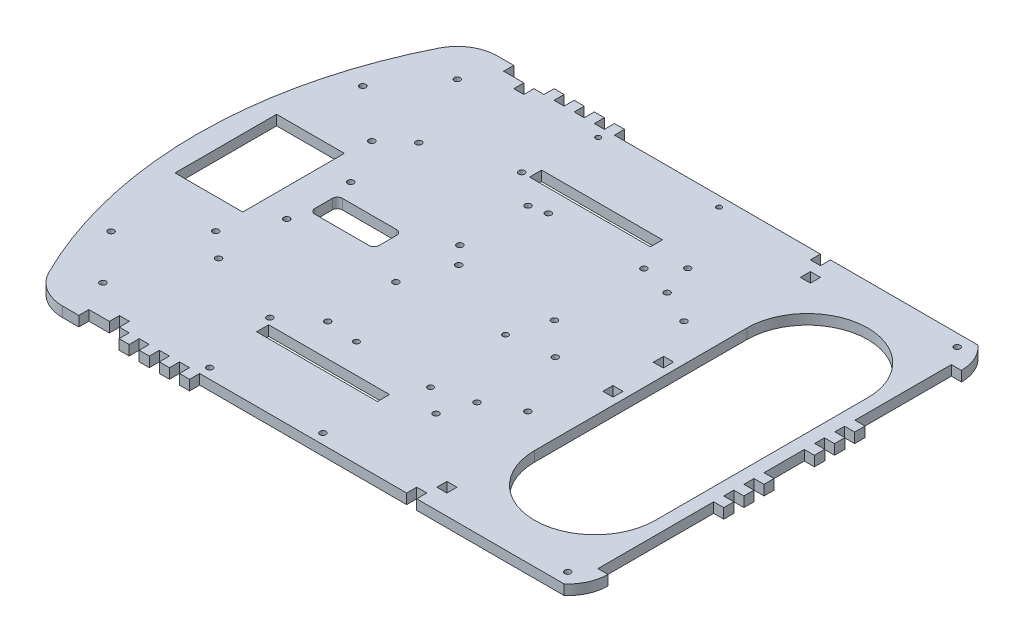
from build123d import *

# Parameters (mm, degrees)
MAIN_BASE_SKETCH_R   = 1.905
MAIN_BASE_SKETCH_R_2 = 1.5875
MAIN_BASE_SKETCH_W   = 6.302603838
MAIN_BASE_SKETCH_H   = 6.555527471
MAIN_BASE_SKETCH_W_2 = 6.35
MAIN_BASE_SKETCH_H_2 = 6.35
MAIN_BASE_SKETCH_W_3 = 76.2
MAIN_BASE_SKETCH_H_3 = 7.62
MAIN_BASE_DEPTH      = 6.35
SKETCH1_R            = 1.905
SKETCH1_R_2          = 1.796
CUT_EXTRUDE1_DEPTH   = 7.35


with BuildPart() as part:
    # main_base_sketch → main_base (new body)
    with BuildSketch(Plane(origin=(0, 0, 0), x_dir=(1, 0, 0), z_dir=(0, 1, 0))):
        with BuildLine():
            Line((-94.961375831, 124.478458264), (-82.261375831, 124.478458264))
            Line((-82.261375831, 124.478458264), (-82.261375831, 118.128458264))
            Line((-82.261375831, 118.128458264), (-75.911375831, 118.128458264))
            Line((-75.911375831, 118.128458264), (-75.911375831, 124.478458264))
            Line((-75.911375831, 124.478458264), (-69.561375831, 124.478458264))
            Line((-69.561375831, 124.478458264), (-69.561375831, 130.828458264))
            Line((-69.561375831, 130.828458264), (-63.211375831, 130.828458264))
            Line((-63.211375831, 130.828458264), (-63.211375831, 124.478458264))
            Line((-63.211375831, 124.478458264), (-56.861375831, 124.478458264))
            Line((-56.861375831, 124.478458264), (-56.861375831, 130.828458264))
            Line((-56.861375831, 130.828458264), (-50.511375831, 130.828458264))
            Line((-50.511375831, 130.828458264), (-50.511375831, 124.478458264))
            Line((-50.511375831, 124.478458264), (-44.161375831, 124.478458264))
            Line((-44.161375831, 124.478458264), (-44.161375831, 130.828458264))
            Line((-44.161375831, 130.828458264), (-37.811375831, 130.828458264))
            Line((-37.811375831, 130.828458264), (-37.811375831, 124.478458264))
            Line((-37.811375831, 124.478458264), (-31.461375831, 124.478458264))
            Line((-31.461375831, 124.478458264), (-31.461375831, 130.828458264))
            Line((-31.461375831, 130.828458264), (-25.111375831, 130.828458264))
            Line((-25.111375831, 130.828458264), (-25.111375831, 124.478458264))
            Line((-25.111375831, 124.478458264), (104.775, 124.478458264))
            Line((104.775, 124.478458264), (104.775, 118.128458264))
            Line((104.775, 118.128458264), (111.125, 118.128458264))
            Line((111.125, 118.128458264), (111.125, 124.478458264))
            Line((111.125, 124.478458264), (113.566844105, 124.478458264))
            Line((113.566844105, 124.478458264), (204.125520825, 124.478458264))
            ThreePointArc((204.125520825, 124.478458264), (210.475520825, 115.878979089), (212.725, 105.428458264))
            Line((212.725, 105.428458264), (206.375, 105.428458264))
            Line((206.375, 105.428458264), (206.375, 44.655527471))
            Line((206.375, 44.655527471), (212.725, 44.655527471))
            Line((212.725, 44.655527471), (212.725, 38.1))
            Line((212.725, 38.1), (206.375, 38.1))
            Line((206.375, 38.1), (206.375, 31.955527471))
            Line((206.375, 31.955527471), (212.725, 31.955527471))
            Line((212.725, 31.955527471), (212.725, 25.4))
            Line((212.725, 25.4), (206.375, 25.4))
            Line((206.375, 25.4), (206.375, 24.179190074))
            Line((206.375, 24.179190074), (206.375, 19.255527471))
            Line((206.375, 19.255527471), (212.725, 19.255527471))
            Line((212.725, 19.255527471), (212.725, 12.7))
            Line((212.725, 12.7), (206.375, 12.7))
            Line((206.375, 12.7), (206.375, -12.7))
            Line((206.375, -12.7), (212.725, -12.7))
            Line((212.725, -12.7), (212.725, -19.05))
            Line((212.725, -19.05), (206.375, -19.05))
            Line((206.375, -19.05), (206.375, -25.4))
            Line((206.375, -25.4), (212.725, -25.4))
            Line((212.725, -25.4), (212.725, -31.75))
            Line((212.725, -31.75), (206.375, -31.75))
            Line((206.375, -31.75), (206.375, -38.1))
            Line((206.375, -38.1), (212.725, -38.1))
            Line((212.725, -38.1), (212.725, -44.45))
            Line((212.725, -44.45), (206.375, -44.45))
            Line((206.375, -44.45), (206.375, -117.410242597))
            Line((206.375, -117.410242597), (212.725, -117.410242597))
            ThreePointArc((212.725, -117.410242597), (210.475520825, -127.860763422), (204.125520825, -136.460242597))
            Line((204.125520825, -136.460242597), (111.125, -136.460242597))
            Line((111.125, -136.460242597), (111.125, -130.101785028))
            Line((111.125, -130.101785028), (104.775, -130.101785028))
            Line((104.775, -130.101785028), (104.775, -136.460242597))
            Line((104.775, -136.460242597), (-25.751645083, -136.460242597))
            Line((-25.751645083, -136.460242597), (-25.751645083, -142.810242597))
            Line((-25.751645083, -142.810242597), (-32.101645083, -142.810242597))
            Line((-32.101645083, -142.810242597), (-32.101645083, -136.460242597))
            Line((-32.101645083, -136.460242597), (-38.451645083, -136.460242597))
            Line((-38.451645083, -136.460242597), (-38.451645083, -142.810242597))
            Line((-38.451645083, -142.810242597), (-44.801645083, -142.810242597))
            Line((-44.801645083, -142.810242597), (-44.801645083, -136.460242597))
            Line((-44.801645083, -136.460242597), (-51.151645083, -136.460242597))
            Line((-51.151645083, -136.460242597), (-51.151645083, -142.810242597))
            Line((-51.151645083, -142.810242597), (-57.501645083, -142.810242597))
            Line((-57.501645083, -142.810242597), (-57.501645083, -136.460242597))
            Line((-57.501645083, -136.460242597), (-63.851645083, -136.460242597))
            Line((-63.851645083, -136.460242597), (-63.851645083, -142.810242597))
            Line((-63.851645083, -142.810242597), (-70.201645083, -142.810242597))
            Line((-70.201645083, -142.810242597), (-70.201645083, -136.460242597))
            Line((-70.201645083, -136.460242597), (-76.408932816, -136.460242597))
            Line((-76.408932816, -136.460242597), (-76.408932816, -130.101785028))
            Line((-76.408932816, -130.101785028), (-82.6643, -130.101785028))
            Line((-82.6643, -130.101785028), (-82.6643, -136.460242597))
            Line((-82.6643, -136.460242597), (-95.601645083, -136.460242597))
            Line((-95.601645083, -136.460242597), (-95.601645083, -142.810242597))
            Line((-95.601645083, -142.810242597), (-105.798207048, -142.810242597))
            ThreePointArc((-105.798207048, -142.810242597), (-119.167015715, -139.007347839), (-128.532661201, -128.737404395))
            ThreePointArc((-128.532661201, -128.737404395), (-157.286213724, -5.861503432), (-127.918775374, 116.869125935))
            ThreePointArc((-127.918775374, 116.869125935), (-118.556014486, 127.058910858), (-105.241228699, 130.828458264))
            Line((-105.241228699, 130.828458264), (-94.961375831, 130.828458264))
            Line((-94.961375831, 130.828458264), (-94.961375831, 124.478458264))
        make_face()
        with Locations((-131.296368682, 71.963600743)):
            Circle(MAIN_BASE_SKETCH_R, mode=Mode.SUBTRACT)
        with Locations((-131.296368682, -86.786399257)):
            Circle(MAIN_BASE_SKETCH_R, mode=Mode.SUBTRACT)
        with Locations((198.617679728, 116.869125935)):
            Circle(MAIN_BASE_SKETCH_R, mode=Mode.SUBTRACT)
        with Locations((198.617679728, -128.737404395)):
            Circle(MAIN_BASE_SKETCH_R, mode=Mode.SUBTRACT)
        with Locations((-105.241228699, 105.428458264)):
            Circle(MAIN_BASE_SKETCH_R, mode=Mode.SUBTRACT)
        with Locations((-105.798207048, -117.410242597)):
            Circle(MAIN_BASE_SKETCH_R, mode=Mode.SUBTRACT)
        with Locations((-29.019531727, 118.128458264)):
            Circle(MAIN_BASE_SKETCH_R_2, mode=Mode.SUBTRACT)
        with Locations((47.180468273, 118.128458264)):
            Circle(MAIN_BASE_SKETCH_R_2, mode=Mode.SUBTRACT)
        with Locations((-25.751645083, -130.101785028)):
            Circle(MAIN_BASE_SKETCH_R, mode=Mode.SUBTRACT)
        with Locations((45.623485648, -130.101785028)):
            Circle(MAIN_BASE_SKETCH_R, mode=Mode.SUBTRACT)
        Polygon((-143.056346513, 19.225219085), (-143.056346513, 29.385219085), (-132.896346513, 29.385219085), (-110.497281748, 29.385219085), (-100.337281748, 29.385219085), (-100.337281748, 19.225219085), (-100.337281748, -24.529097407), (-100.337281748, -34.689097407), (-110.497281748, -34.689097407), (-132.896346513, -34.689097407), (-143.056346513, -34.689097407), (-143.056346513, -24.529097407), align=None, mode=Mode.SUBTRACT)
        with Locations((114.276301919, 15.977763736)):
            Rectangle(MAIN_BASE_SKETCH_W, MAIN_BASE_SKETCH_H, mode=Mode.SUBTRACT)
        with Locations((114.3, -15.875)):
            Rectangle(MAIN_BASE_SKETCH_W_2, MAIN_BASE_SKETCH_H_2, mode=Mode.SUBTRACT)
        with Locations((114.3, 108.603458264)):
            Rectangle(MAIN_BASE_SKETCH_W_2, MAIN_BASE_SKETCH_H_2, mode=Mode.SUBTRACT)
        with Locations((114.3, -120.585242597)):
            Rectangle(MAIN_BASE_SKETCH_W_2, MAIN_BASE_SKETCH_H_2, mode=Mode.SUBTRACT)
        with Locations((9.080468273, 78.663485503)):
            Rectangle(MAIN_BASE_SKETCH_W_3, MAIN_BASE_SKETCH_H_3, mode=Mode.SUBTRACT)
        with Locations((7.523485648, -91.897827751)):
            Rectangle(MAIN_BASE_SKETCH_W_3, MAIN_BASE_SKETCH_H_3, mode=Mode.SUBTRACT)
        with BuildLine():
            Line((121.92, 60.978458264), (121.92, -72.960242597))
            ThreePointArc((121.92, -72.960242597), (160.02, -111.060242597), (198.12, -72.960242597))
            Line((198.12, -72.960242597), (198.12, 60.978458264))
            ThreePointArc((198.12, 60.978458264), (160.02, 99.078458264), (121.92, 60.978458264))
        make_face(mode=Mode.SUBTRACT)
    extrude(amount=MAIN_BASE_DEPTH)

    # Sketch1 → Cut-Extrude1 (cut, through all)
    with BuildSketch(Plane(origin=(0, 6.35, 0), x_dir=(1, 0, 0), z_dir=(0, 1, 0))):
        with Locations((-82.6643, 58.691593479)):
            Circle(SKETCH1_R)
        with Locations((-13.8303, 58.691593479)):
            Circle(SKETCH1_R)
        with Locations((-3.2843, 60.939493479)):
            Circle(SKETCH1_R)
        with Locations((-13.8303, 15.689393479)):
            Circle(SKETCH1_R)
        with Locations((-3.2843, 4.475293479)):
            Circle(SKETCH1_R)
        with Locations((-82.6643, 15.689393479)):
            Circle(SKETCH1_R)
        with Locations((-82.6643, -24.620406521)):
            Circle(SKETCH1_R)
        with Locations((-13.8303, -24.620406521)):
            Circle(SKETCH1_R)
        with Locations((-82.6643, -67.622606521)):
            Circle(SKETCH1_R)
        with Locations((-13.8303, -67.622606521)):
            Circle(SKETCH1_R)
        with Locations((6.29, -69.601706521)):
            Circle(SKETCH1_R_2)
        with Locations((54.55, -71.189206521)):
            Circle(SKETCH1_R_2)
        with Locations((49.47, -18.801706521)):
            Circle(SKETCH1_R_2)
        with Locations((57.0407, 4.475293479)):
            Circle(SKETCH1_R)
        with Locations((57.0407, 60.939493479)):
            Circle(SKETCH1_R)
        with Locations((-98.425, 44.768293479)):
            Circle(SKETCH1_R)
        with Locations((-34.0871, 74.909493479)):
            Circle(SKETCH1_R)
        with Locations((70.6863, 74.909493479)):
            Circle(SKETCH1_R)
        with Locations((98.425, 44.768293479)):
            Circle(SKETCH1_R)
        with Locations((98.425, -53.699306521)):
            Circle(SKETCH1_R)
        with Locations((70.6863, -83.840506521)):
            Circle(SKETCH1_R)
        with Locations((-34.0871, -83.840506521)):
            Circle(SKETCH1_R)
        with Locations((-98.425, -53.699306521)):
            Circle(SKETCH1_R)
        with Locations((77.47, -64.790506521)):
            Circle(SKETCH1_R)
        with Locations((77.47, 55.065743479)):
            Circle(SKETCH1_R)
        with Locations((77.47, -15.419256521)):
            Circle(SKETCH1_R)
        with BuildLine():
            Line((-42.259046148, -13.14715688), (-76.408932816, -13.14715688))
            ThreePointArc((-76.408932816, -13.14715688), (-78.653996846, -12.21722091), (-79.583932816, -9.97215688))
            Line((-79.583932816, -9.97215688), (-79.583932816, 1.041143838))
            ThreePointArc((-79.583932816, 1.041143838), (-78.653996846, 3.286207868), (-76.408932816, 4.216143838))
            Line((-76.408932816, 4.216143838), (-42.259046148, 4.216143838))
            ThreePointArc((-42.259046148, 4.216143838), (-40.013982118, 3.286207868), (-39.084046148, 1.041143838))
            Line((-39.084046148, 1.041143838), (-39.084046148, -9.97215688))
            ThreePointArc((-39.084046148, -9.97215688), (-40.013982118, -12.21722091), (-42.259046148, -13.14715688))
        make_face()
    extrude(amount=-CUT_EXTRUDE1_DEPTH, mode=Mode.SUBTRACT)


solid = part.part
